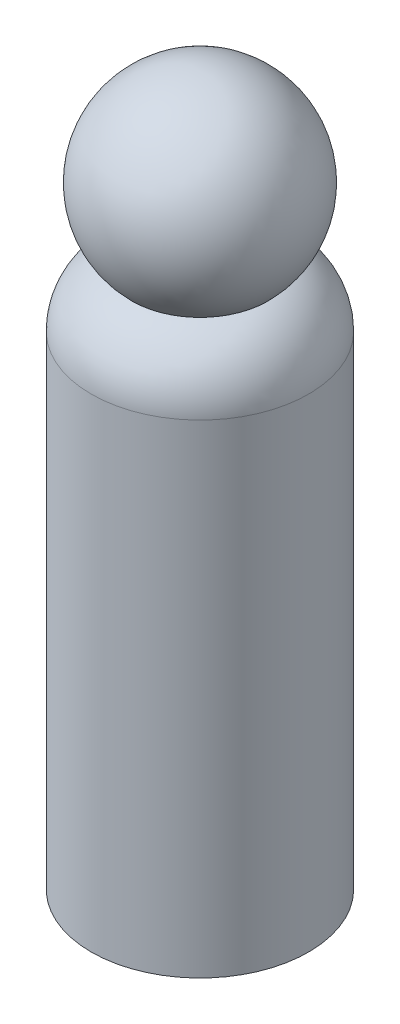
from build123d import *


with BuildPart() as part:
    # Sketch1 → Revolve1 (revolve)
    with BuildSketch(Plane.XY):
        with BuildLine():
            Line((0, 0), (-21.43125, 0))
            Line((-21.43125, 0), (-21.43125, 95.25))
            ThreePointArc((-21.43125, 95.25), (-19.222517349, 102.407046138), (-13.3645871, 107.074643222))
            ThreePointArc((-13.3645871, 107.074643222), (-17.628287589, 127.87121712), (0, 139.7))
            Line((0, 139.7), (0, 0))
        make_face()
    revolve(axis=Axis((0, 139.7, 0), (0, -1, 0)))


solid = part.part
